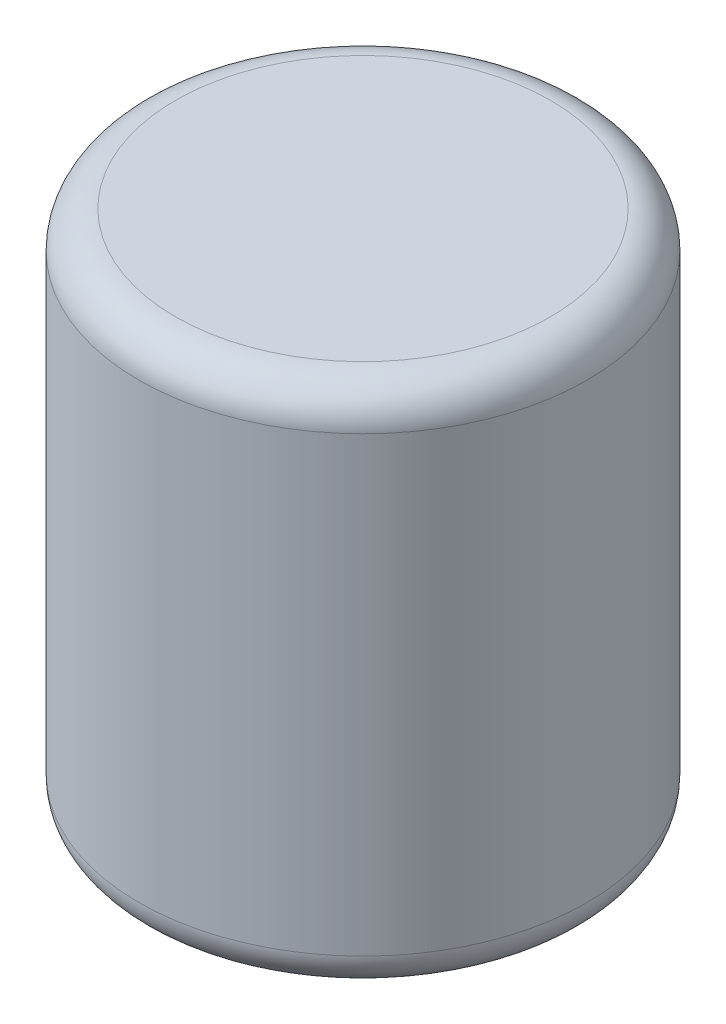
from build123d import *

# Parameters (mm, degrees)
SKETCH1_R           = 31.115
BOSS_EXTRUDE1_DEPTH = 72.9742
FILLET1_R           = 5.08


with BuildPart() as part:
    # Sketch1 → Boss-Extrude1 (new body)
    with BuildSketch(Plane(origin=(0, 0, 0), x_dir=(1, 0, 0), z_dir=(0, 1, 0))):
        Circle(SKETCH1_R)
    extrude(amount=BOSS_EXTRUDE1_DEPTH)

    # Fillet1
    fillet1_edges = [part.edges().sort_by_distance(p)[0] for p in [
        (-31.115, 0, 0),
        (-31.115, 72.9742, 0),
    ]]
    fillet(fillet1_edges, radius=FILLET1_R)


solid = part.part
